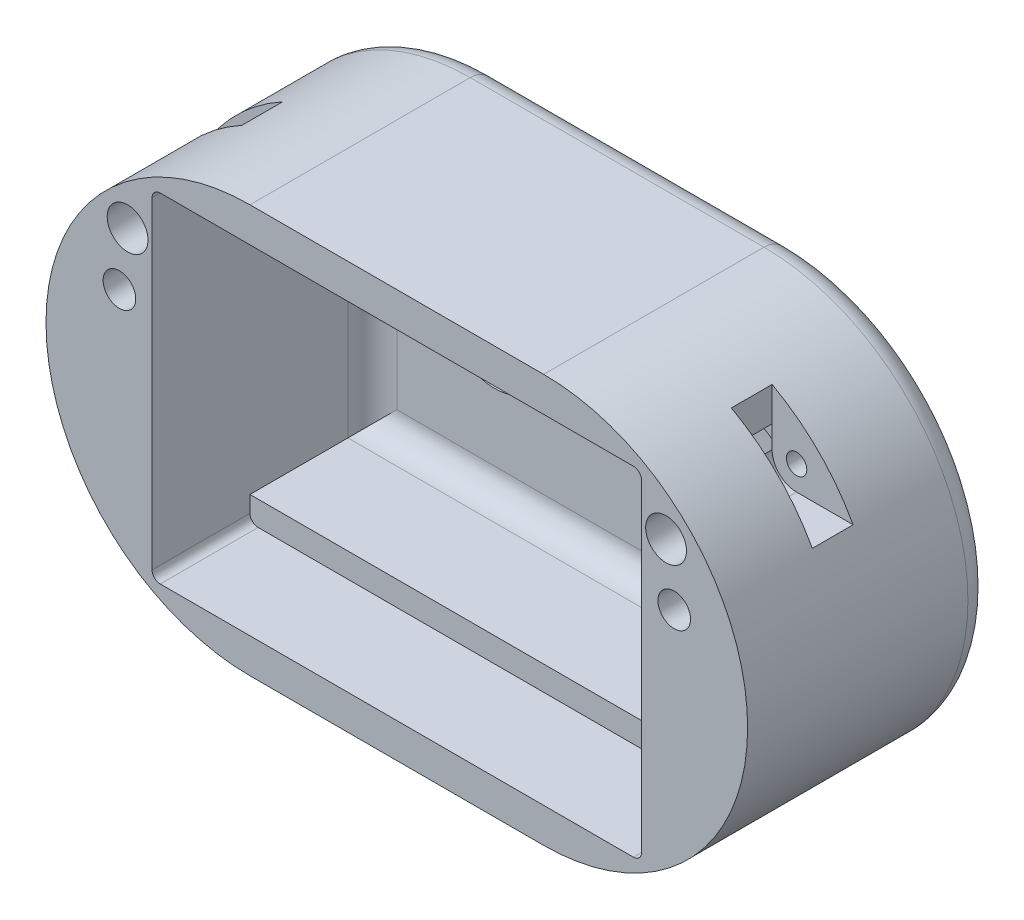
from build123d import *

# Parameters (mm, degrees)
BOSS_EXTRUDE1_DEPTH = 30
SKETCH2_W           = 60
SKETCH2_H           = 41.5
CUT_EXTRUDE1_DEPTH  = 27
SKETCH5_W           = 60
SKETCH5_H           = 3
BOSS_EXTRUDE2_DEPTH = 15
FILLET2_R           = 1
FILLET3_R           = 3
FILLET4_R           = 3
CUT_EXTRUDE2_START  = 14
CUT_EXTRUDE2_DEPTH  = 5
CUT_EXTRUDE3_START  = -30
SKETCH7_R           = 1.25
CUT_EXTRUDE3_DEPTH  = 25
SKETCH8_R           = 2.5
CUT_EXTRUDE4_DEPTH  = 4
SKETCH9_R           = 6.5
CUT_EXTRUDE5_DEPTH  = 1.75
SKETCH10_R          = 2
CUT_EXTRUDE6_DEPTH  = 31
SKETCH11_R          = 3.5
CUT_EXTRUDE7_DEPTH  = 10


with BuildPart() as part:
    # Sketch1 → Boss-Extrude1 (new body)
    with BuildSketch(Plane.XY):
        with BuildLine():
            Line((-18, 25), (18, 25))
            ThreePointArc((18, 25), (43, 0), (18, -25))
            Line((18, -25), (-18, -25))
            ThreePointArc((-18, -25), (-43, 0), (-18, 25))
        make_face()
    extrude(amount=BOSS_EXTRUDE1_DEPTH)

    # Sketch2 → Cut-Extrude1 (cut)
    with BuildSketch(Plane.XY.offset(30)):
        Rectangle(SKETCH2_W, SKETCH2_H)
    extrude(amount=-CUT_EXTRUDE1_DEPTH, mode=Mode.SUBTRACT)

    # Sketch5 → Boss-Extrude2 (add)
    with BuildSketch(Plane.XY.offset(3)):
        with Locations((0, 19.25)):
            Rectangle(SKETCH5_W, SKETCH5_H)
        with Locations((0, -19.25)):
            Rectangle(SKETCH5_W, SKETCH5_H)
    extrude(amount=BOSS_EXTRUDE2_DEPTH)

    # Fillet2
    fillet2_edges = [part.edges().sort_by_distance(p)[0] for p in [
        (-30, 20.75, 24),
        (30, 20.75, 24),
        (30, -20.75, 24),
        (-30, -20.75, 24),
    ]]
    fillet(fillet2_edges, radius=FILLET2_R)

    # Fillet3
    fillet3_edges = [part.edges().sort_by_distance(p)[0] for p in [
        (-30, 0, 3),
        (0, 17.75, 3),
        (30, 0, 3),
        (0, -17.75, 3),
    ]]
    fillet(fillet3_edges, radius=FILLET3_R)

    # Fillet4
    fillet4_edges = [part.edges().sort_by_distance(p)[0] for p in [
        (0, 25, 0),
        (43, 0, 0),
        (0, -25, 0),
        (-43, 0, 0),
    ]]
    fillet(fillet4_edges, radius=FILLET4_R)

    # Sketch6 → Cut-Extrude2 (cut)
    with BuildSketch(Plane.XY.offset(CUT_EXTRUDE2_START)):
        with BuildLine():
            Line((-44.296401613, 12), (-33, 12))
            ThreePointArc((-33, 12), (-30.878679656, 12.878679656), (-30, 15))
            Line((-30, 15), (-30, 24.104241325))
            Line((-30, 24.104241325), (-44.296401613, 12))
        make_face()
        with BuildLine():
            Line((30, 24.104241325), (44.296401613, 12))
            Line((44.296401613, 12), (33, 12))
            ThreePointArc((33, 12), (30.878679656, 12.878679656), (30, 15))
            Line((30, 15), (30, 24.104241325))
        make_face()
    extrude(amount=CUT_EXTRUDE2_DEPTH, mode=Mode.SUBTRACT)

    # Sketch7 → Cut-Extrude3 (cut)
    with BuildSketch(Plane(origin=(0, 0, 0), x_dir=(-1, 0, 0), z_dir=(0, 0, -1)).offset(CUT_EXTRUDE3_START)):
        with Locations((-33, 15)):
            Circle(SKETCH7_R)
    cut_extrude3 = extrude(amount=CUT_EXTRUDE3_DEPTH, mode=Mode.SUBTRACT)

    # Sketch8 → Cut-Extrude4 (cut)
    with BuildSketch(Plane.XY.offset(30)):
        with Locations((33, 15)):
            Circle(SKETCH8_R)
    cut_extrude4 = extrude(amount=-CUT_EXTRUDE4_DEPTH, mode=Mode.SUBTRACT)

    # Mirror1: Cut-Extrude3, Cut-Extrude4 across plane
    add(cut_extrude3.mirror(Plane(origin=(0, 0, 0), x_dir=(0, 0, 1), z_dir=(1, 0, 0))), mode=Mode.SUBTRACT)
    add(cut_extrude4.mirror(Plane(origin=(0, 0, 0), x_dir=(0, 0, 1), z_dir=(1, 0, 0))), mode=Mode.SUBTRACT)

    # Sketch9 → Cut-Extrude5 (cut)
    with BuildSketch(Plane.XY.offset(3)):
        with Locations((-15, 0)):
            Circle(SKETCH9_R)
        with Locations((15, 0)):
            Circle(SKETCH9_R)
    extrude(amount=-CUT_EXTRUDE5_DEPTH, mode=Mode.SUBTRACT)

    # Sketch10 → Cut-Extrude6 (cut, through all)
    with BuildSketch(Plane(origin=(0, 0, 0), x_dir=(-1, 0, 0), z_dir=(0, 0, -1))):
        with Locations((-34, 8)):
            Circle(SKETCH10_R)
        with Locations((34, 8)):
            Circle(SKETCH10_R)
    extrude(amount=-CUT_EXTRUDE6_DEPTH, mode=Mode.SUBTRACT)

    # Sketch11 → Cut-Extrude7 (cut)
    with BuildSketch(Plane(origin=(0, 0, 0), x_dir=(-1, 0, 0), z_dir=(0, 0, -1))):
        with Locations((-34, 8)):
            Circle(SKETCH11_R)
        with Locations((34, 8)):
            Circle(SKETCH11_R)
    extrude(amount=-CUT_EXTRUDE7_DEPTH, mode=Mode.SUBTRACT)


solid = part.part
